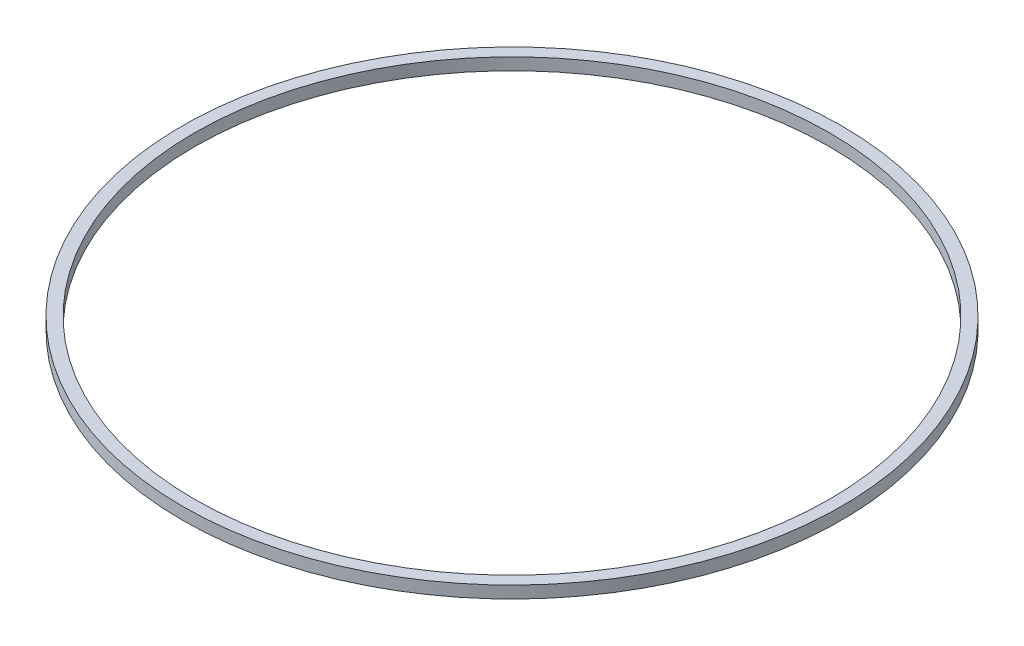
from build123d import *

# Parameters (mm, degrees)
SKETCH1_W = 76.2
SKETCH1_H = 76.2


with BuildPart() as part:
    # Sketch1 → Revolve1 (revolve)
    with BuildSketch(Plane.XY):
        with Locations((2038.1, 0)):
            Rectangle(SKETCH1_W, SKETCH1_H)
    revolve(axis=Axis((0, 0, 0), (0, 1, 0)))


solid = part.part
